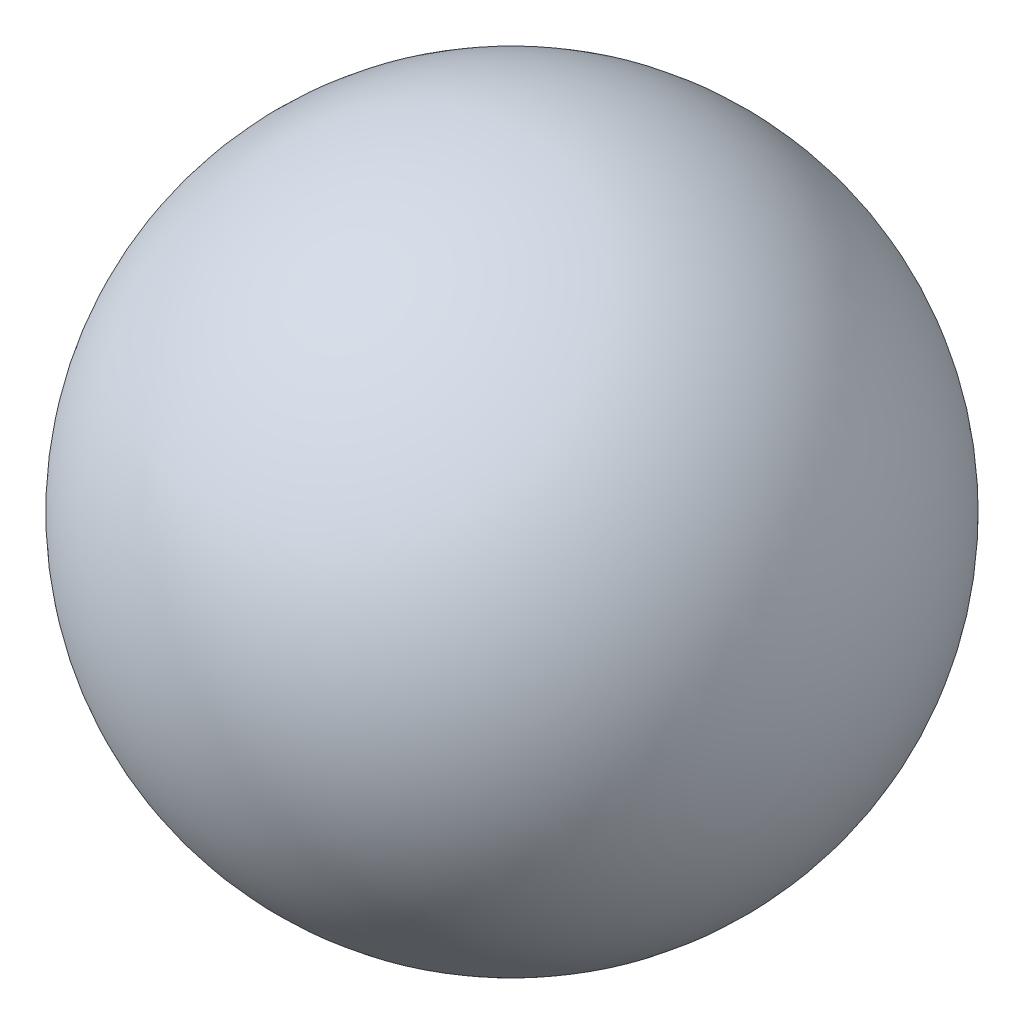
from build123d import *


with BuildPart() as part:
    # Sketch1 → Revolve1 (revolve)
    with BuildSketch(Plane.XY):
        with BuildLine():
            Line((0, -9.5), (0, 9.5))
            ThreePointArc((0, 9.5), (9.5, 0), (0, -9.5))
        make_face()
    revolve(axis=Axis((0, -9.5, 0), (0, 1, 0)))


solid = part.part
